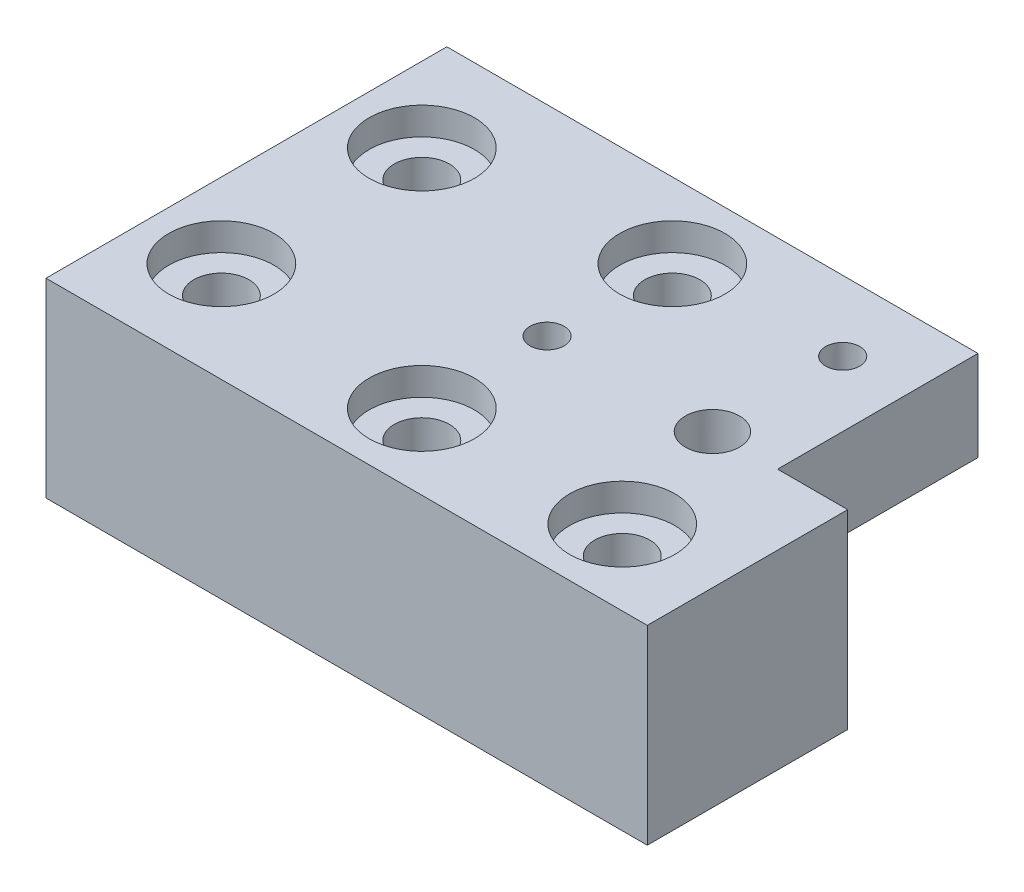
from build123d import *

# Parameters (mm, degrees)
BOSS_EXTRUDE1_DEPTH             = 10
BOSS_EXTRUDE2_DEPTH             = 9
CBORE_FOR_M5_SBHCS1_D           = 5.5
CBORE_FOR_M5_SBHCS1_CBORE_D     = 10.5
CBORE_FOR_M5_SBHCS1_CBORE_DEPTH = 2.75
CBORE_FOR_M5_SBHCS2_D           = 5.5
CBORE_FOR_M5_SBHCS2_CBORE_D     = 10.5
CBORE_FOR_M5_SBHCS2_CBORE_DEPTH = 2.75
CBORE_FOR_M3_SBHCS1_D           = 3.4
CBORE_FOR_M3_SBHCS1_CBORE_D     = 6.7
CBORE_FOR_M3_SBHCS1_CBORE_DEPTH = 16
CBORE_FOR_M3_SBHCS2_D           = 3.4
CBORE_FOR_M3_SBHCS2_CBORE_D     = 6.7
CBORE_FOR_M3_SBHCS2_CBORE_DEPTH = 6
F_5_4_5_4_DIAMETER_HOLE1_D      = 5.4


with BuildPart() as part:
    # Sketch1 → Boss-Extrude1 (new body)
    with BuildSketch(Plane(origin=(0, 0, 0), x_dir=(1, 0, 0), z_dir=(0, 1, 0))):
        Polygon((0, 0), (60, 0), (60, 40), (20, 40), (20, 20), (0, 20), align=None)
    extrude(amount=BOSS_EXTRUDE1_DEPTH)

    # Sketch2 → Boss-Extrude2 (add)
    with BuildSketch(Plane(origin=(0, 10, 0), x_dir=(1, 0, 0), z_dir=(0, 1, 0))):
        Polygon((20, 40), (7, 40), (7, 20), (0, 20), (0, 0), (60, 0), (60, 40), align=None)
    extrude(amount=BOSS_EXTRUDE2_DEPTH)

    # CBORE for M5 SBHCS1 (through all)
    with Locations(Plane(origin=(0, 19, 0), x_dir=(1, 0, 0), z_dir=(0, 1, 0))):
        with Locations((10, 7.5), (30, 7.5), (30, 32.5)):
            CounterBoreHole(CBORE_FOR_M5_SBHCS1_D / 2, CBORE_FOR_M5_SBHCS1_CBORE_D / 2, CBORE_FOR_M5_SBHCS1_CBORE_DEPTH)

    # CBORE for M5 SBHCS2 (through all)
    with Locations(Plane(origin=(0, 19, 0), x_dir=(1, 0, 0), z_dir=(0, 1, 0))):
        with Locations((52.5, 30), (52.5, 10)):
            CounterBoreHole(CBORE_FOR_M5_SBHCS2_D / 2, CBORE_FOR_M5_SBHCS2_CBORE_D / 2, CBORE_FOR_M5_SBHCS2_CBORE_DEPTH)

    # CBORE for M3 SBHCS1 (through all)
    with Locations(Plane(origin=(0, 0, 0), x_dir=(-1, 0, 0), z_dir=(0, -1, 0))):
        with Locations((-30, 20)):
            CounterBoreHole(CBORE_FOR_M3_SBHCS1_D / 2, CBORE_FOR_M3_SBHCS1_CBORE_D / 2, CBORE_FOR_M3_SBHCS1_CBORE_DEPTH)

    # CBORE for M3 SBHCS2 (through all)
    with Locations(Plane(origin=(0, 10, 0), x_dir=(-1, 0, 0), z_dir=(0, -1, 0))):
        with Locations((-13.5, 33)):
            CounterBoreHole(CBORE_FOR_M3_SBHCS2_D / 2, CBORE_FOR_M3_SBHCS2_CBORE_D / 2, CBORE_FOR_M3_SBHCS2_CBORE_DEPTH)

    # Ø5.4 (5.4) Diameter Hole1 (through all)
    with Locations(Plane(origin=(0, 0, 0), x_dir=(-1, 0, 0), z_dir=(0, -1, 0))):
        with Locations((-13.5, 20)):
            Hole(F_5_4_5_4_DIAMETER_HOLE1_D / 2)


with BuildPart() as body_2:
    # Mirror1: mirrored copy
    add(part.part.mirror(Plane(origin=(60, 10, 0), x_dir=(0, 0, 1), z_dir=(-1, 0, 0))))


solid = body_2.part
